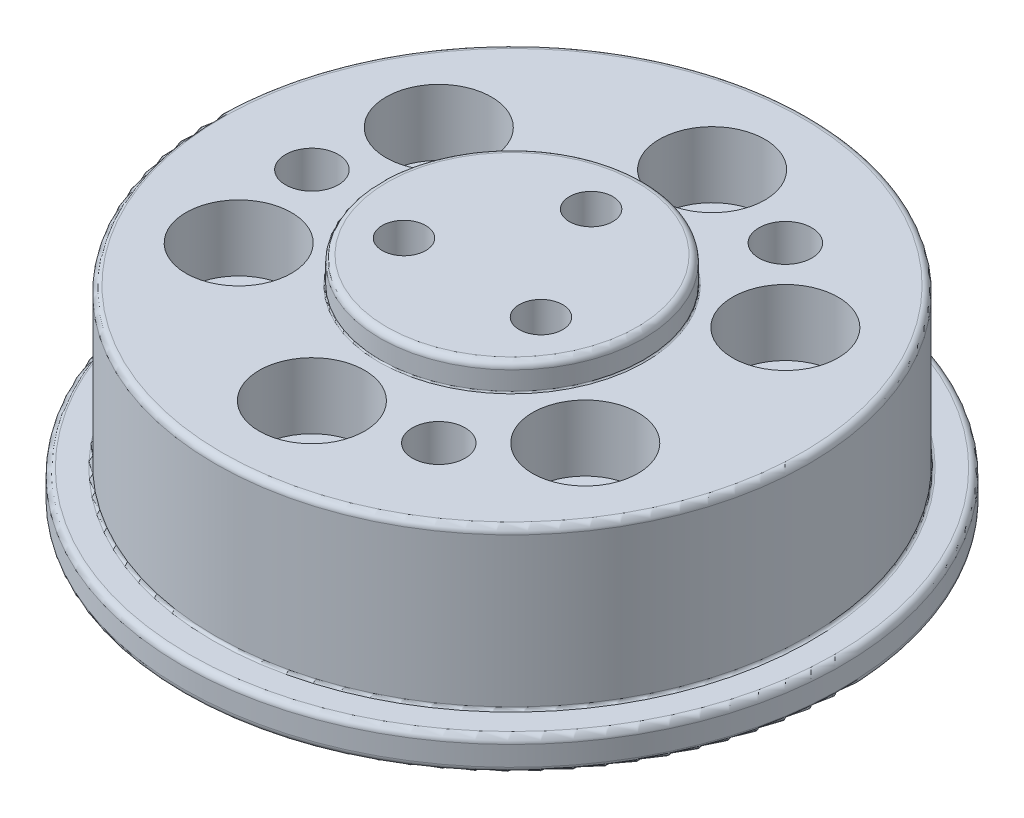
from build123d import *

# Parameters (mm, degrees)
SKETCH_1_R                   = 10.1
EXTRUDE_1_DEPTH              = 2.5
SKETCH_2_R                   = 25
EXTRUDE_2_DEPTH              = 2.5
SKETCH_3_R                   = 22.5
EXTRUDE_4_DEPTH              = 12
SKETCH_5_R                   = 10
EXTRUDE_5_DEPTH              = 2
HOLE_WIZARD_M4_1_D           = 4.5
HOLE_WIZARD_M4_1_CBORE_D     = 8
HOLE_WIZARD_M4_1_CBORE_DEPTH = 5
PATTERN_CIRCULAR_1_COUNT     = 6
PATTERN_CIRCULAR_2_COUNT     = 3
FILLET_1_R                   = 0.5
FILLET_2_R                   = 0.2
FILLET_3_R                   = 0.1
FILLET_4_R                   = 0.5
F_4_0MM_1_D                  = 4
PATTERN_CIRCULAR_3_COUNT     = 3


with BuildPart() as part:
    # 스케치1 → 보스-돌출1 (new body)
    with BuildSketch(Plane(origin=(0, 0, 0), x_dir=(1, 0, 0), z_dir=(0, 1, 0))):
        Circle(SKETCH_1_R)
    extrude(amount=EXTRUDE_1_DEPTH)

    # 스케치2 → 보스-돌출2 (add)
    with BuildSketch(Plane(origin=(0, 2.5, 0), x_dir=(1, 0, 0), z_dir=(0, 1, 0))):
        Circle(SKETCH_2_R)
    extrude(amount=EXTRUDE_2_DEPTH)

    # 스케치3 → 보스-돌출4 (add)
    with BuildSketch(Plane(origin=(0, 5, 0), x_dir=(1, 0, 0), z_dir=(0, 1, 0))):
        Circle(SKETCH_3_R)
    extrude(amount=EXTRUDE_4_DEPTH)

    # 스케치5 → 보스-돌출5 (add)
    with BuildSketch(Plane(origin=(0, 17, 0), x_dir=(1, 0, 0), z_dir=(0, 1, 0))):
        Circle(SKETCH_5_R)
    extrude(amount=EXTRUDE_5_DEPTH)

    # Hole Wizard M4 _ _ _ _ _ _1 (through all)
    with Locations(Plane(origin=(0, 17, 0), x_dir=(1, 0, 0), z_dir=(0, 1, 0))):
        with Locations((0, 15.18)):
            hole_wizard_m4_1 = CounterBoreHole(HOLE_WIZARD_M4_1_D / 2, HOLE_WIZARD_M4_1_CBORE_D / 2, HOLE_WIZARD_M4_1_CBORE_DEPTH)

    # 원형 패턴1: Hole Wizard M4 _ _ _ _ _ _1 ×6 about axis
    pattern_circular_1_axis = Axis((0, 0, 0), (0, 1, 0))
    for i in range(1, PATTERN_CIRCULAR_1_COUNT):
        add(hole_wizard_m4_1.rotate(pattern_circular_1_axis, i * 360 / PATTERN_CIRCULAR_1_COUNT), mode=Mode.SUBTRACT)

    # 스케치13 → Hole Wizard M4 _ _ _ _1 2 (revolve, cut)
    with BuildSketch(Plane(origin=(0, 19, -6), x_dir=(0, 0, 1), z_dir=(1, 0, 0))):
        Polygon((0, 0), (0, 5.991420021), (1.65, 5), (1.65, 0), align=None)
    hole_wizard_m4_1_2 = revolve(axis=Axis((0, 25.35, -6), (0, -1, 0)), mode=Mode.SUBTRACT)

    # 원형 패턴2: Hole Wizard M4 _ _ _ _1 2 ×3 about axis
    pattern_circular_2_axis = Axis((0, 0, 0), (0, 1, 0))
    for i in range(1, PATTERN_CIRCULAR_2_COUNT):
        add(hole_wizard_m4_1_2.rotate(pattern_circular_2_axis, i * 360 / PATTERN_CIRCULAR_2_COUNT), mode=Mode.SUBTRACT)

    # 필렛1
    fillet_1_edges = [part.edges().sort_by_distance(p)[0] for p in [
        (-22.5, 17, 0),
        (-10.1, 0, 0),
        (-10.1, 2.5, 0),
        (-25, 2.5, 0),
        (-25, 5, 0),
    ]]
    fillet(fillet_1_edges, radius=FILLET_1_R)

    # 필렛2
    fillet_2_edges = [part.edges().sort_by_distance(p)[0] for p in [
        (-22.5, 5, 0),
    ]]
    fillet(fillet_2_edges, radius=FILLET_2_R)

    # 필렛3
    fillet_3_edges = [part.edges().sort_by_distance(p)[0] for p in [
        (-10, 17, 0),
    ]]
    fillet(fillet_3_edges, radius=FILLET_3_R)

    # 필렛4
    fillet_4_edges = [part.edges().sort_by_distance(p)[0] for p in [
        (-10, 19, 0),
    ]]
    fillet(fillet_4_edges, radius=FILLET_4_R)

    # Ø4.0mm 맞춤핀 구멍1 (through all)
    with Locations(Plane(origin=(0, 17, 0), x_dir=(1, 0, 0), z_dir=(0, 1, 0))):
        with Locations((-15.18, 0)):
            f_4_0mm_1 = Hole(F_4_0MM_1_D / 2)

    # 원형 패턴3: Ø4.0mm 맞춤핀 구멍1 ×3 about axis
    pattern_circular_3_axis = Axis((0, 0, 0), (0, 1, 0))
    for i in range(1, PATTERN_CIRCULAR_3_COUNT):
        add(f_4_0mm_1.rotate(pattern_circular_3_axis, i * 360 / PATTERN_CIRCULAR_3_COUNT), mode=Mode.SUBTRACT)


solid = part.part
